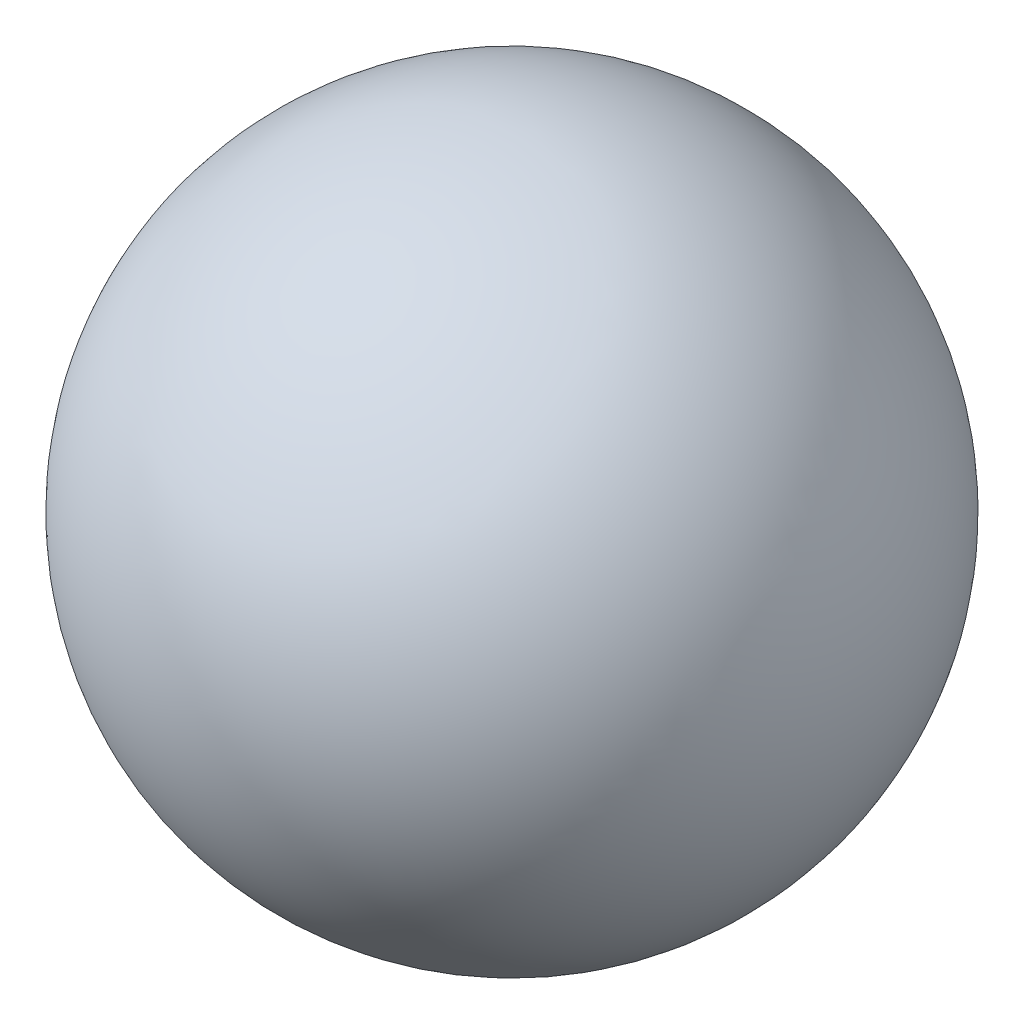
from build123d import *


with BuildPart() as part:
    # Sketch1 → Revolve1 (revolve)
    with BuildSketch(Plane.XY):
        with BuildLine():
            Line((-6.35, 0), (6.35, 0))
            ThreePointArc((6.35, 0), (0, 6.35), (-6.35, 0))
        make_face()
    revolve(axis=Axis((-15.275591218, 0, 0), (1, 0, 0)))


solid = part.part
